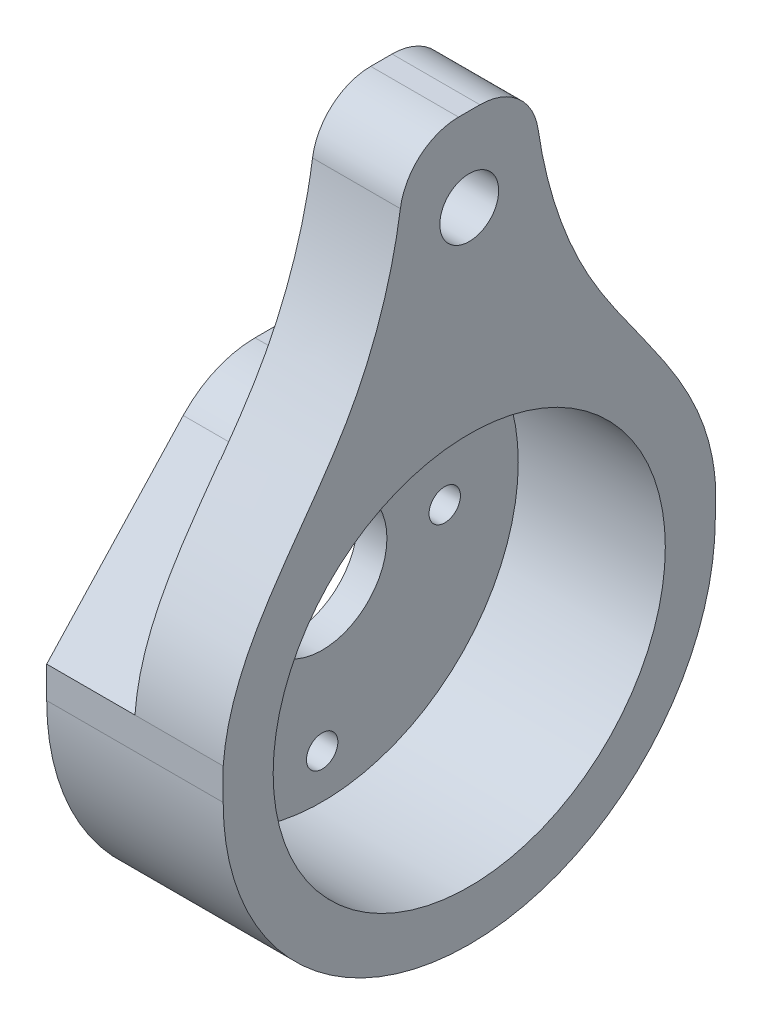
from build123d import *

# Parameters (mm, degrees)
SKETCH1_R               = 10
SKETCH1_R_2             = 0.8
SKETCH1_R_3             = 3.301767793
BOSS_EXTRUDE1_DEPTH     = 1.5
SKETCH2_R               = 10
BOSS_EXTRUDE2_DEPTH     = 9
SKETCH3_R               = 1.5
CUT_EXTRUDE1_DEPTH      = 1
CUT_EXTRUDE1_DEPTH_BACK = 10
FILLET1_R               = 3
CUT_EXTRUDE2_DEPTH      = 10.565166147
CUT_EXTRUDE2_DEPTH_BACK = 16.531923841
CUT_EXTRUDE4_DEPTH      = 4.5
FILLET4_R               = 5


with BuildPart() as part:
    # Sketch1 → Boss-Extrude1 (new body)
    with BuildSketch(Plane(origin=(0, 0, 0), x_dir=(0, 0, -1), z_dir=(1, 0, 0))):
        with Locations((2.983378847, 10.826778074)):
            Circle(SKETCH1_R)
        with Locations((2.983378847, 18.576778074)):
            Circle(SKETCH1_R_2, mode=Mode.SUBTRACT)
        with Locations((2.983378847, 3.076778074)):
            Circle(SKETCH1_R_2, mode=Mode.SUBTRACT)
        with Locations((-3.266621153, 10.826778074)):
            Circle(SKETCH1_R_2, mode=Mode.SUBTRACT)
        with Locations((9.233378847, 10.826778074)):
            Circle(SKETCH1_R_2, mode=Mode.SUBTRACT)
        with Locations((2.983378847, 10.826778074)):
            Circle(SKETCH1_R_3, mode=Mode.SUBTRACT)
    extrude(amount=BOSS_EXTRUDE1_DEPTH)

    # Sketch2 → Boss-Extrude2 (add)
    with BuildSketch(Plane.ZY):
        with BuildLine():
            Line((-15.531923741, 35.094698666), (9.565166047, 35.094698666))
            Line((9.565166047, 35.094698666), (9.565166047, 10.826778074))
            ThreePointArc((9.565166047, 10.826778074), (-2.983378847, -1.721766821), (-15.531923741, 10.826778074))
            Line((-15.531923741, 10.826778074), (-15.531923741, 35.094698666))
        make_face()
        with Locations((-2.983378847, 10.826778074)):
            Circle(SKETCH2_R, mode=Mode.SUBTRACT)
    extrude(amount=-BOSS_EXTRUDE2_DEPTH)

    # Sketch3 → Cut-Extrude1 (cut, two sides)
    with BuildSketch(Plane(origin=(9, 0, 0), x_dir=(0, 0, -1), z_dir=(1, 0, 0))) as cut_extrude1_sk:
        with Locations((2.983378847, 30.826778074)):
            Circle(SKETCH3_R)
        with BuildLine():
            Line((-0.254346927, 36.150412664), (-0.254346927, 97.572569437))
            Line((-0.254346927, 97.572569437), (-16.389018159, 97.572569437))
            Line((-16.389018159, 97.572569437), (-16.389018159, 8.14109285))
            Line((-16.389018159, 8.14109285), (-9.565166047, 10.826778074))
            add(Edge.make_bspline(
                [(-9.565166047, 10.826778074), (-9.996776932, 16.621947073), (-2.416923511, 22.902398079), (-0.279431234, 32.151841163), (-0.254346927, 36.150412664)],
                knots=[0, 0, 0, 0, 0.563274164, 1, 1, 1, 1], degree=3))
        make_face()
        with BuildLine():
            Line((22.355775853, 8.14109285), (15.531923741, 10.826778074))
            add(Edge.make_bspline(
                [(15.531923741, 10.826778074), (15.963534626, 16.621947073), (8.383681205, 22.902398079), (6.246188928, 32.151841163), (6.221104621, 36.150412664)],
                knots=[0, 0, 0, 0, 0.563274164, 1, 1, 1, 1], degree=3))
            Line((6.221104621, 36.150412664), (6.221104621, 97.572569437))
            Line((6.221104621, 97.572569437), (22.355775853, 97.572569437))
            Line((22.355775853, 97.572569437), (22.355775853, 8.14109285))
        make_face()
    extrude(amount=CUT_EXTRUDE1_DEPTH, mode=Mode.SUBTRACT)
    extrude(cut_extrude1_sk.sketch, amount=-CUT_EXTRUDE1_DEPTH_BACK, mode=Mode.SUBTRACT)

    # Fillet1
    fillet1_edges = [part.edges().sort_by_distance(p)[0] for p in [
        (4.5, 35.094698666, -6.248898777),
        (4.5, 35.094698666, 0.282141083),
    ]]
    fillet(fillet1_edges, radius=FILLET1_R)

    # Sketch5 → Cut-Extrude2 (cut, two sides)
    with BuildSketch(Plane.XY) as cut_extrude2_sk:
        Polygon((4.519735145, 37.354194786), (-3.918381593, 39.378706192), (-3.918381593, 21.53545024), (4.519735145, 21.53545024), align=None)
    extrude(amount=CUT_EXTRUDE2_DEPTH, mode=Mode.SUBTRACT)
    extrude(cut_extrude2_sk.sketch, amount=-CUT_EXTRUDE2_DEPTH_BACK, mode=Mode.SUBTRACT)

    # Sketch6 → Cut-Extrude4 (cut)
    with BuildSketch(Plane.ZY):
        Polygon((-15.531923741, 12.43637897), (-7.23722927, 21.53545024), (-16.045201911, 21.53545024), align=None)
        Polygon((9.565166047, 12.43637897), (1.120335679, 21.53545024), (9.021007351, 21.981126747), (10.387134826, 13.199246596), align=None)
    extrude(amount=-CUT_EXTRUDE4_DEPTH, mode=Mode.SUBTRACT)

    # Fillet4
    fillet4_edges = [part.edges().sort_by_distance(p)[0] for p in [
        (2.25, 21.53545024, -7.23722927),
        (2.25, 21.53545024, 1.120335679),
    ]]
    fillet(fillet4_edges, radius=FILLET4_R)


solid = part.part
